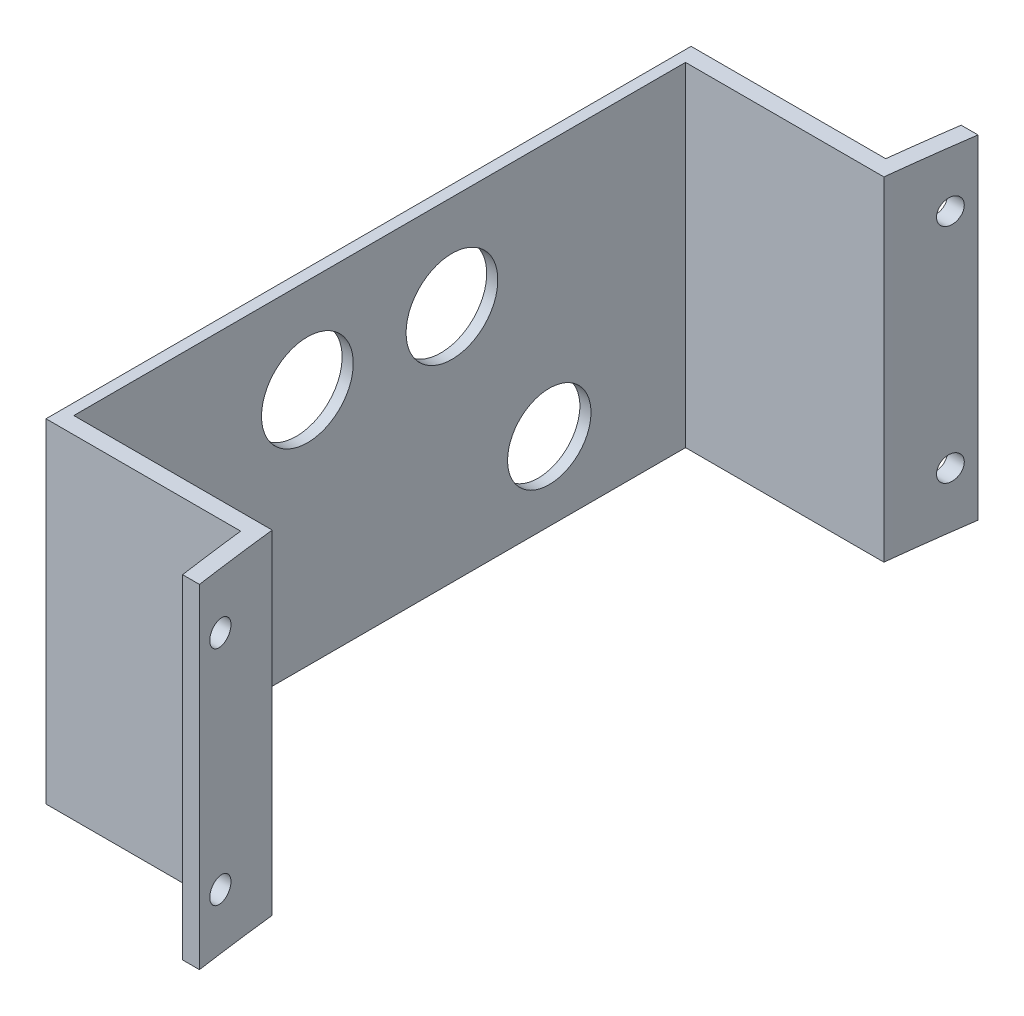
from build123d import *

# Parameters (mm, degrees)
EXTRUDE_1_DEPTH     = 60
SKETCH_3_W          = 110
SKETCH_3_H          = 60
CUT_EXTRUDE_1_DEPTH = 37
SKETCH_4_R          = 7.5
SKETCH_4_R_2        = 8.25
CUT_EXTRUDE_2_DEPTH = 5
SKETCH_7_R          = 2.2
CUT_EXTRUDE_3_DEPTH = 20
SKETCH_7_2_R        = 2.2
CUT_EXTRUDE_4_DEPTH = 9


with BuildPart() as part:
    # Sketch 2 → Extrude 1 (new body)
    with BuildSketch(Plane(origin=(0, 0, 0), x_dir=(1, 0, 0), z_dir=(0, 1, 0))):
        with BuildLine():
            Line((-19.040504883, -60.990225421), (-16.009924796, -60.990225421))
            ThreePointArc((-16.009924796, -60.990225421), (-19.758334463, -26.07939754), (-21.009924796, 9.009774579))
            ThreePointArc((-21.009924796, 9.009774579), (-19.758334463, 44.098946698), (-16.009924796, 79.009774579))
            Line((-16.009924796, 79.009774579), (-19.040504883, 79.009774579))
            ThreePointArc((-19.040504883, 79.009774579), (-19.858720594, 73.014546807), (-20.603665866, 67.009774579))
            Line((-20.603665866, 67.009774579), (-55.603665866, 67.009774579))
            Line((-55.603665866, 67.009774579), (-55.603665866, -48.990225421))
            Line((-55.603665866, -48.990225421), (-20.603665866, -48.990225421))
            ThreePointArc((-20.603665866, -48.990225421), (-19.858720594, -54.99499765), (-19.040504883, -60.990225421))
        make_face()
    extrude(amount=EXTRUDE_1_DEPTH)

    # Sketch 3 → Cut-Extrude 1 (cut)
    with BuildSketch(Plane.ZY.offset(16.603665866)):
        with Locations((-9.009774579, 30)):
            Rectangle(SKETCH_3_W, SKETCH_3_H)
    extrude(amount=CUT_EXTRUDE_1_DEPTH, mode=Mode.SUBTRACT)

    # Sketch 4 → Cut-Extrude 2 (cut)
    with BuildSketch(Plane.ZY.offset(55.603665866)):
        with Locations((21.490225421, 14)):
            Circle(SKETCH_4_R)
        with Locations((-39.509774579, 14)):
            Circle(SKETCH_4_R)
        with Locations((3.990225421, 43)):
            Circle(SKETCH_4_R_2)
        with Locations((-22.009774579, 43)):
            Circle(SKETCH_4_R_2)
    extrude(amount=-CUT_EXTRUDE_2_DEPTH, mode=Mode.SUBTRACT)

    # Sketch 7 → Cut-Extrude 3 (cut)
    with BuildSketch(Plane.ZY.offset(16.603665866)):
        with Locations(Location((-74.648328965, 50, 0), (0, 0, 180))):  # turned: the seam where the file's is
            Circle(SKETCH_7_R)
        with Locations(Location((-74.648328965, 10, 0), (0, 0, 180))):  # turned: the seam where the file's is
            Circle(SKETCH_7_R)
        with Locations(Location((56.628779808, 50, 0), (0, 0, 180))):  # turned: the seam where the file's is
            Circle(SKETCH_7_R)
        with Locations(Location((56.628779808, 10, 0), (0, 0, 180))):  # turned: the seam where the file's is
            Circle(SKETCH_7_R)
    extrude(amount=CUT_EXTRUDE_3_DEPTH, mode=Mode.SUBTRACT)

    # Sketch 7_2 → Cut-Extrude 4 (cut)
    with BuildSketch(Plane.ZY.offset(16.603665866)):
        with Locations(Location((-74.648328965, 50, 0), (0, 0, 180))):  # turned: the seam where the file's is
            Circle(SKETCH_7_2_R)
        with Locations(Location((-74.648328965, 10, 0), (0, 0, 180))):  # turned: the seam where the file's is
            Circle(SKETCH_7_2_R)
        with Locations(Location((56.628779808, 50, 0), (0, 0, 180))):  # turned: the seam where the file's is
            Circle(SKETCH_7_2_R)
        with Locations(Location((56.628779808, 10, 0), (0, 0, 180))):  # turned: the seam where the file's is
            Circle(SKETCH_7_2_R)
    extrude(amount=-CUT_EXTRUDE_4_DEPTH, mode=Mode.SUBTRACT)


solid = part.part
